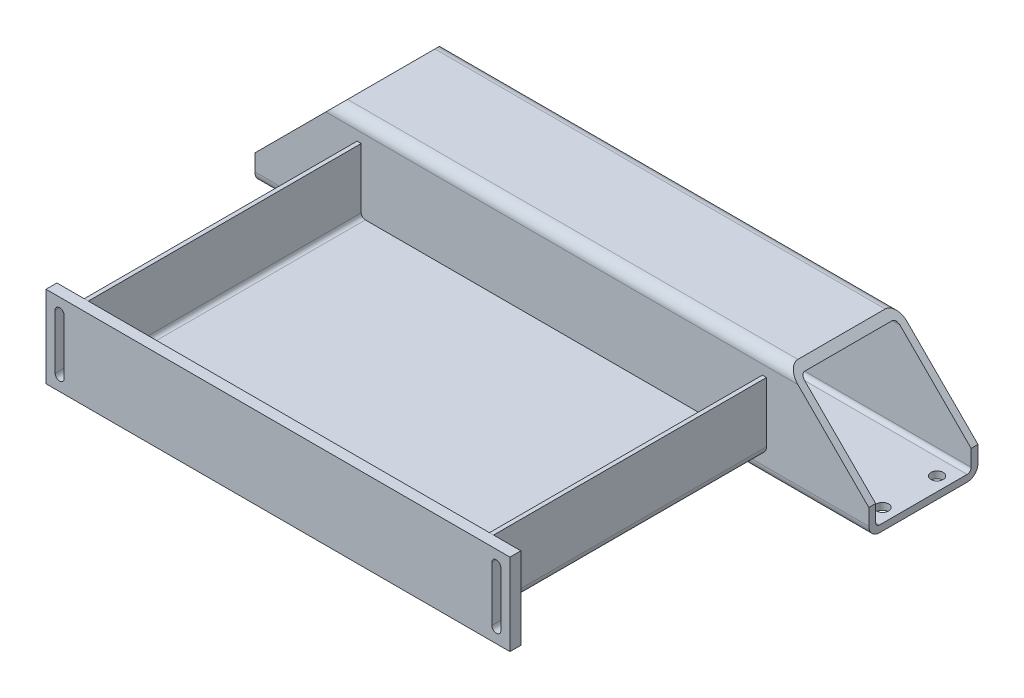
from build123d import *

# Parameters (mm, degrees)
AUFSATZ_LINEAR_AUSTRAGEN1_DEPTH = 100
SKIZZE2_W                       = 340
SKIZZE2_H                       = 60
AUFSATZ_LINEAR_AUSTRAGEN2_DEPTH = 8
AUFSATZ_LINEAR_AUSTRAGEN3_DEPTH = 1.5
SCHNITT_LINEAR_AUSTRAGEN1_DEPTH = 209
AUFSATZ_LINEAR_AUSTRAGEN4_DEPTH = 225
SCHNITT_LINEAR_AUSTRAGEN2_DEPTH = 289
SKIZZE8_R                       = 4.5
SCHNITT_LINEAR_AUSTRAGEN3_DEPTH = 81


with BuildPart() as part:
    # Skizze1 → Aufsatz-Linear austragen1 (new body, symmetric)
    with BuildSketch(Plane.XY):
        with BuildLine():
            Line((-150, 50), (-150, 6))
            ThreePointArc((-150, 6), (-148.242640687, 1.757359313), (-144, 0))
            Line((-144, 0), (144, 0))
            ThreePointArc((144, 0), (148.242640687, 1.757359313), (150, 6))
            Line((150, 6), (150, 50))
            Line((150, 50), (147, 50))
            Line((147, 50), (147, 6))
            ThreePointArc((147, 6), (146.121320344, 3.878679656), (144, 3))
            Line((144, 3), (-144, 3))
            ThreePointArc((-144, 3), (-146.121320344, 3.878679656), (-147, 6))
            Line((-147, 6), (-147, 50))
            Line((-147, 50), (-150, 50))
        make_face()
    extrude(amount=AUFSATZ_LINEAR_AUSTRAGEN1_DEPTH, both=True)


with BuildPart() as body_2:
    # Skizze2 → Aufsatz-Linear austragen2 (new body)
    with BuildSketch(Plane.XY.offset(100)):
        with Locations((0, 20)):
            Rectangle(SKIZZE2_W, SKIZZE2_H)
    extrude(amount=AUFSATZ_LINEAR_AUSTRAGEN2_DEPTH)

    # Skizze5 → Schnitt-Linear austragen1 (cut, through all)
    with BuildSketch(Plane.XY.offset(108)):
        with BuildLine():
            Line((163.3, 0), (163.3, 40))
            ThreePointArc((163.3, 40), (160, 43.3), (156.7, 40))
            Line((156.7, 40), (156.7, 0))
            ThreePointArc((156.7, 0), (160, -3.3), (163.3, 0))
        make_face()
    schnitt_linear_austragen1 = extrude(amount=-SCHNITT_LINEAR_AUSTRAGEN1_DEPTH, mode=Mode.SUBTRACT)

    # Spiegeln1: Schnitt-Linear austragen1 across plane
    add(schnitt_linear_austragen1.mirror(Plane(origin=(0, 0, 0), x_dir=(0, 0, 1), z_dir=(1, 0, 0))), mode=Mode.SUBTRACT)


with BuildPart() as body_3:
    # Skizze4 → Aufsatz-Linear austragen3 (new body, symmetric)
    with BuildSketch(Plane(origin=(0, 0, 0), x_dir=(0, 0, -1), z_dir=(1, 0, 0))):
        Polygon((-100, 45), (-95, 45), (-58, 8), (-58, 3), (-100, 3), align=None)
    extrude(amount=AUFSATZ_LINEAR_AUSTRAGEN3_DEPTH, both=True)


with BuildPart() as body_4:
    # Skizze6 → Aufsatz-Linear austragen4 (new body, symmetric)
    with BuildSketch(Plane(origin=(0, 0, 0), x_dir=(0, 0, -1), z_dir=(1, 0, 0))):
        with BuildLine():
            Line((108, -15), (172, -15))
            ThreePointArc((172, -15), (177.656854249, -12.656854249), (180, -7))
            Line((180, -7), (180, 57))
            ThreePointArc((180, 57), (177.656854249, 62.656854249), (172, 65))
            Line((172, 65), (108, 65))
            ThreePointArc((108, 65), (102.343145751, 62.656854249), (100, 57))
            Line((100, 57), (100, -7))
            ThreePointArc((100, -7), (102.343145751, -12.656854249), (108, -15))
        make_face()
        with BuildLine():
            Line((108, 60), (172, 60))
            ThreePointArc((172, 60), (174.121320344, 59.121320344), (175, 57))
            Line((175, 57), (175, -7))
            ThreePointArc((175, -7), (174.121320344, -9.121320344), (172, -10))
            Line((172, -10), (108, -10))
            ThreePointArc((108, -10), (105.878679656, -9.121320344), (105, -7))
            Line((105, -7), (105, 57))
            ThreePointArc((105, 57), (105.878679656, 59.121320344), (108, 60))
        make_face(mode=Mode.SUBTRACT)
    extrude(amount=AUFSATZ_LINEAR_AUSTRAGEN4_DEPTH, both=True)

    # Skizze7 → Schnitt-Linear austragen2 (cut, through all)
    with BuildSketch(Plane(origin=(0, 0, -180), x_dir=(-1, 0, 0), z_dir=(0, 0, -1))):
        Polygon((-225, 5), (-165, 65), (-225, 65), align=None)
        Polygon((225, 65), (225, 5), (165, 65), align=None)
    extrude(amount=-SCHNITT_LINEAR_AUSTRAGEN2_DEPTH, mode=Mode.SUBTRACT)

    # Skizze8 → Schnitt-Linear austragen3 (cut, through all)
    with BuildSketch(Plane.XZ.offset(15)):
        with Locations(Location((215, -160, 0), (0, 0, 270))):  # turned: the seam where the file's is
            Circle(SKIZZE8_R)
        with Locations(Location((215, -120, 0), (0, 0, 90))):  # turned: the seam where the file's is
            Circle(SKIZZE8_R)
        with Locations(Location((-215, -160, 0), (0, 0, 90))):  # turned: the seam where the file's is
            Circle(SKIZZE8_R)
        with Locations(Location((-215, -120, 0), (0, 0, 270))):  # turned: the seam where the file's is
            Circle(SKIZZE8_R)
    extrude(amount=-SCHNITT_LINEAR_AUSTRAGEN3_DEPTH, mode=Mode.SUBTRACT)


solid = Compound([part.part, body_2.part, body_3.part, body_4.part])
